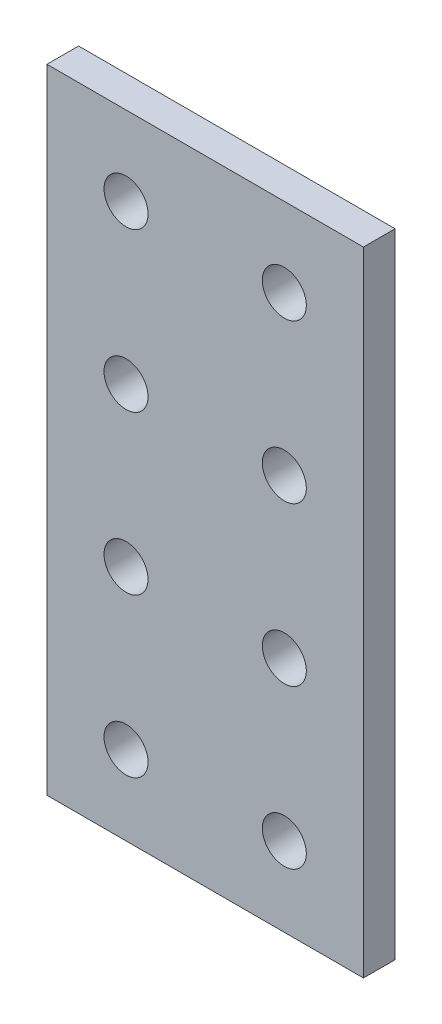
from build123d import *

# Parameters (mm, degrees)
SKETCH1_W           = 40
SKETCH1_H           = 80
SKETCH1_R           = 2.78
BOSS_EXTRUDE1_DEPTH = 4


with BuildPart() as part:
    # Sketch1 → Boss-Extrude1 (new body)
    with BuildSketch(Plane.XY.offset(4)):
        with Locations((0, 40)):
            Rectangle(SKETCH1_W, SKETCH1_H)
        with Locations((-10, 70)):
            Circle(SKETCH1_R, mode=Mode.SUBTRACT)
        with Locations((-10, 50)):
            Circle(SKETCH1_R, mode=Mode.SUBTRACT)
        with Locations((-10, 30)):
            Circle(SKETCH1_R, mode=Mode.SUBTRACT)
        with Locations((-10, 10)):
            Circle(SKETCH1_R, mode=Mode.SUBTRACT)
        with Locations((10, 70)):
            Circle(SKETCH1_R, mode=Mode.SUBTRACT)
        with Locations((10, 50)):
            Circle(SKETCH1_R, mode=Mode.SUBTRACT)
        with Locations((10, 30)):
            Circle(SKETCH1_R, mode=Mode.SUBTRACT)
        with Locations((10, 10)):
            Circle(SKETCH1_R, mode=Mode.SUBTRACT)
    extrude(amount=-BOSS_EXTRUDE1_DEPTH)


solid = part.part
